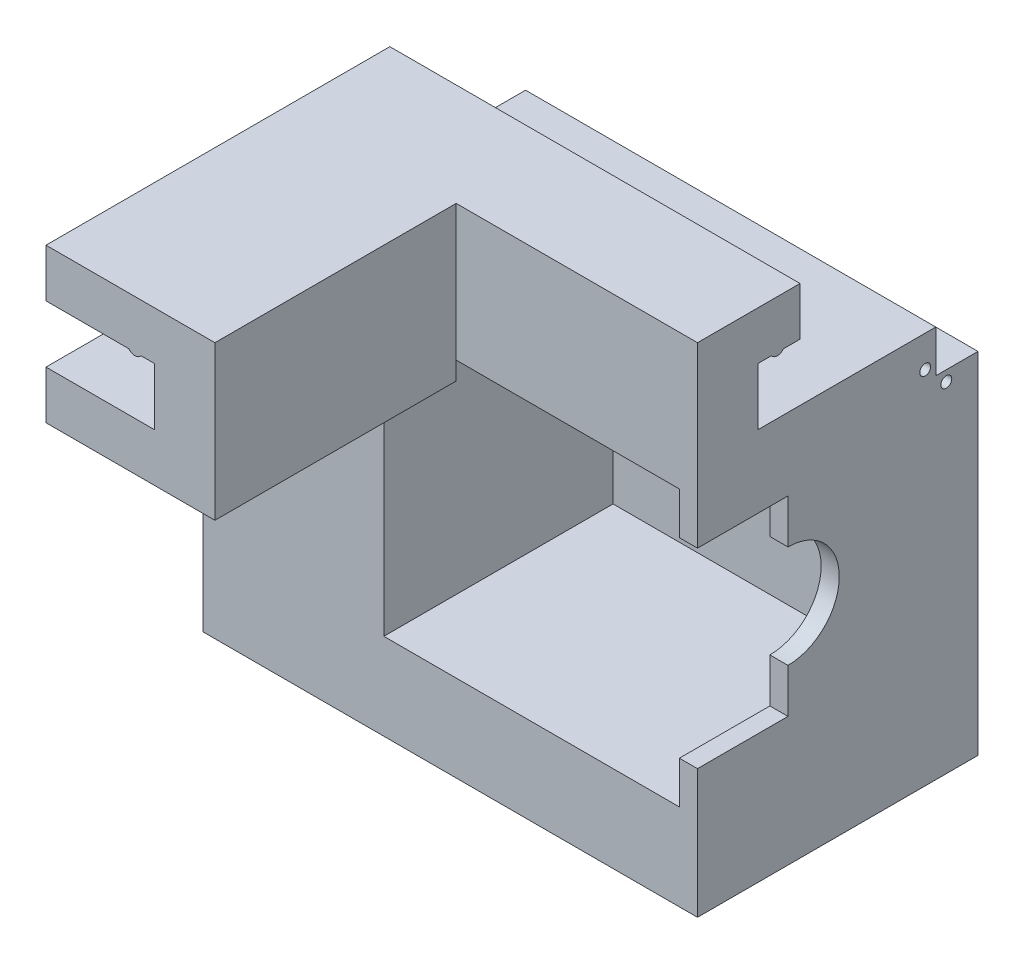
from build123d import *

# Parameters (mm, degrees)
BOSS_EXTRUDE1_DEPTH = 50
SKETCH2_W           = 7
SKETCH2_H           = 8
BOSS_EXTRUDE2_DEPTH = 50
SKETCH2_3_W         = 7
SKETCH2_3_H         = 8
BOSS_EXTRUDE3_DEPTH = 18
SKETCH3_W           = 10
SKETCH3_H           = 63
SKETCH3_W_2         = 7
SKETCH3_H_2         = 8
BOSS_EXTRUDE4_DEPTH = 82
FILLET1_R           = 5
SKETCH4_W           = 49
SKETCH4_H           = 29.5
CUT_EXTRUDE1_DEPTH  = 63
SKETCH5_W           = 29.5
SKETCH5_H           = 11
BOSS_EXTRUDE5_DEPTH = 49
CUT_EXTRUDE2_DEPTH  = 29.5
SKETCH6_R           = 1.75
CUT_EXTRUDE3_DEPTH  = 5
SKETCH6_6_R         = 0.75
CUT_EXTRUDE4_DEPTH  = 15
SKETCH8_W           = 18
SKETCH8_H           = 9.5
CUT_EXTRUDE5_DEPTH  = 40
SKETCH9_W           = 7
SKETCH9_H           = 9.5
CUT_EXTRUDE6_DEPTH  = 45
SKETCH10_W          = 10
SKETCH10_H          = 10
CUT_EXTRUDE7_DEPTH  = 29.5
SKETCH11_W          = 13
SKETCH11_H          = 48
SKETCH11_H_2        = 7
CUT_EXTRUDE8_DEPTH  = 124.13610356
SKETCH12_W          = 8
SKETCH12_H          = 10
CUT_EXTRUDE9_DEPTH  = 114.279521539
SKETCH13_W          = 10
SKETCH13_H          = 6
CUT_EXTRUDE10_DEPTH = 14
SKETCH15_W          = 14
SKETCH15_H          = 6
CUT_EXTRUDE11_DEPTH = 128.218316291
FILLET2_R           = 3
SKETCH17_W          = 49
SKETCH17_H          = 62
BOSS_EXTRUDE6_DEPTH = 46.5
CUT_EXTRUDE12_START = -30
SKETCH18_W          = 45
SKETCH18_H          = 63
CUT_EXTRUDE12_DEPTH = 30
SKETCH19_W          = 45
SKETCH19_H          = 4
SKETCH19_H_2        = 27.35
BOSS_EXTRUDE7_DEPTH = 30
BOSS_EXTRUDE8_DEPTH = 3
SKETCH24_W          = 14
SKETCH24_H          = 10
CUT_EXTRUDE15_DEPTH = 112.778799421
SKETCH26_W          = 42
SKETCH26_H          = 31.65
CUT_EXTRUDE16_DEPTH = 8
SKETCH27_W          = 42
SKETCH27_H          = 38
CUT_EXTRUDE17_DEPTH = 7
SKETCH28_W          = 42
SKETCH28_H          = 38
CUT_EXTRUDE18_DEPTH = 7
SKETCH29_W          = 38
SKETCH29_H          = 45.65
CUT_EXTRUDE19_DEPTH = 7
SKETCH30_W          = 46.5
SKETCH30_H          = 6
CUT_EXTRUDE20_DEPTH = 131.599578866
CUT_EXTRUDE21_DEPTH = 127.610623567
SKETCH32_3_R        = 0.9
SKETCH32_3_R_2      = 0.75
CUT_EXTRUDE22_DEPTH = 6


with BuildPart() as part:
    # Sketch1 → Boss-Extrude1 (new body)
    with BuildSketch(Plane.XY):
        with BuildLine():
            Line((-2.25, -8), (-4.25, -8))
            ThreePointArc((-4.25, -8), (-3.25, -8.5), (-2.25, -8))
        make_face()
        Polygon((10, -25.5), (10, 0), (0, 0), (-18, 0), (-18, -8), (0, -8), (0, -17.5), (-18, -17.5), (-18, -25.5), align=None)
    extrude(amount=BOSS_EXTRUDE1_DEPTH)

    # Sketch2 → Boss-Extrude2 (add)
    with BuildSketch(Plane(origin=(0, 0, 0), x_dir=(0, 0, -1), z_dir=(1, 0, 0))):
        Polygon((7, 0), (0, 0), (0, -8), (2.25, -8), (4.25, -8), (7, -8), align=None)
        Polygon((0, -8), (0, 0), (-10, 0), (-10, -25.5), (0, -25.5), (0, -17.5), align=None)
        with Locations((3.5, -21.5)):
            Rectangle(SKETCH2_W, SKETCH2_H)
        with BuildLine():
            Line((4.25, -8), (2.25, -8))
            ThreePointArc((2.25, -8), (3.25, -8.5), (4.25, -8))
        make_face()
    extrude(amount=BOSS_EXTRUDE2_DEPTH)

    # Sketch2_3 → Boss-Extrude3 (add)
    with BuildSketch(Plane(origin=(0, 0, 0), x_dir=(0, 0, -1), z_dir=(1, 0, 0))):
        Polygon((7, 0), (0, 0), (0, -8), (2.25, -8), (4.25, -8), (7, -8), align=None)
        with Locations((3.5, -21.5)):
            Rectangle(SKETCH2_3_W, SKETCH2_3_H)
    extrude(amount=-BOSS_EXTRUDE3_DEPTH)

    # Sketch3 → Boss-Extrude4 (add)
    with BuildSketch(Plane(origin=(50, 0, 0), x_dir=(0, 0, -1), z_dir=(1, 0, 0))):
        Polygon((36.5, -17.5), (7, -17.5), (7, -25.5), (0, -25.5), (0, -88.5), (36.5, -88.5), align=None)
        with Locations((-5, -57)):
            Rectangle(SKETCH3_W, SKETCH3_H)
        with Locations((3.5, -21.5)):
            Rectangle(SKETCH3_W_2, SKETCH3_H_2)
        with Locations((-5, -21.5)):
            Rectangle(SKETCH3_W, SKETCH3_H_2)
    extrude(amount=-BOSS_EXTRUDE4_DEPTH)

    # Fillet1
    fillet1_edges = [part.edges().sort_by_distance(p)[0] for p in [
        (-32, -17.5, -13.25),
        (-32, -53, -36.5),
        (9, -17.5, -36.5),
    ]]
    fillet(fillet1_edges, radius=FILLET1_R)

    # Sketch4 → Cut-Extrude1 (cut)
    with BuildSketch(Plane.XZ.offset(88.5)):
        with Locations((25.5, -4.75)):
            Rectangle(SKETCH4_W, SKETCH4_H)
    extrude(amount=-CUT_EXTRUDE1_DEPTH, mode=Mode.SUBTRACT)

    # Sketch5 → Boss-Extrude5 (add)
    with BuildSketch(Plane(origin=(50, 0, 0), x_dir=(0, 0, -1), z_dir=(1, 0, 0))):
        with Locations((4.75, -31)):
            Rectangle(SKETCH5_W, SKETCH5_H)
        with Locations((4.75, -83)):
            Rectangle(SKETCH5_W, SKETCH5_H)
    extrude(amount=-BOSS_EXTRUDE5_DEPTH)

    # Sketch7 → Cut-Extrude2 (cut)
    with BuildSketch(Plane.XY.offset(10)):
        Polygon((1, -36.5), (27, -36.5), (27, -26.5), (50, -26.5), (50, -88.5), (27, -88.5), (27, -77.5), (1, -77.5), align=None)
    extrude(amount=-CUT_EXTRUDE2_DEPTH, mode=Mode.SUBTRACT)

    # Sketch6 → Cut-Extrude3 (cut)
    with BuildSketch(Plane(origin=(27, 0, 0), x_dir=(0, 0, -1), z_dir=(1, 0, 0))):
        with Locations((4.25, -81.5)):
            Circle(SKETCH6_R)
        with Locations((14.25, -81.5)):
            Circle(SKETCH6_R)
        with Locations((14.25, -32.5)):
            Circle(SKETCH6_R)
        with Locations((4.25, -32.5)):
            Circle(SKETCH6_R)
    extrude(amount=-CUT_EXTRUDE3_DEPTH, mode=Mode.SUBTRACT)

    # Sketch6_6 → Cut-Extrude4 (cut)
    with BuildSketch(Plane(origin=(27, 0, 0), x_dir=(0, 0, -1), z_dir=(1, 0, 0))):
        with Locations((4.25, -81.5)):
            Circle(SKETCH6_6_R)
        with Locations((14.25, -81.5)):
            Circle(SKETCH6_6_R)
        with Locations((14.25, -32.5)):
            Circle(SKETCH6_6_R)
        with Locations((4.25, -32.5)):
            Circle(SKETCH6_6_R)
    extrude(amount=-CUT_EXTRUDE4_DEPTH, mode=Mode.SUBTRACT)

    # Sketch8 → Cut-Extrude5 (cut)
    with BuildSketch(Plane(origin=(0, 0, -7), x_dir=(-1, 0, 0), z_dir=(0, 0, -1))):
        with Locations((9, -12.75)):
            Rectangle(SKETCH8_W, SKETCH8_H)
    extrude(amount=-CUT_EXTRUDE5_DEPTH, mode=Mode.SUBTRACT)

    # Sketch9 → Cut-Extrude6 (cut)
    with BuildSketch(Plane.ZY.offset(18)):
        with Locations((-3.5, -12.75)):
            Rectangle(SKETCH9_W, SKETCH9_H)
    extrude(amount=-CUT_EXTRUDE6_DEPTH, mode=Mode.SUBTRACT)

    # Sketch10 → Cut-Extrude7 (cut)
    with BuildSketch(Plane.XY.offset(10)):
        with Locations((6, -31.5)):
            Rectangle(SKETCH10_W, SKETCH10_H)
    extrude(amount=-CUT_EXTRUDE7_DEPTH, mode=Mode.SUBTRACT)

    # Sketch11 → Cut-Extrude8 (cut, through all)
    with BuildSketch(Plane.XY.offset(-19.5)):
        with Locations((43.5, -57.5)):
            Rectangle(SKETCH11_W, SKETCH11_H)
        with Locations((43.5, -85)):
            Rectangle(SKETCH11_W, SKETCH11_H_2)
    extrude(amount=-CUT_EXTRUDE8_DEPTH, mode=Mode.SUBTRACT)

    # Sketch12 → Cut-Extrude9 (cut, through all)
    with BuildSketch(Plane.XZ.offset(88.5)):
        with Locations((-28, -31.5)):
            Rectangle(SKETCH12_W, SKETCH12_H)
    extrude(amount=-CUT_EXTRUDE9_DEPTH, mode=Mode.SUBTRACT)

    # Sketch13 → Cut-Extrude10 (cut)
    with BuildSketch(Plane.ZY.offset(32)):
        with Locations((-31.5, -20.5)):
            Rectangle(SKETCH13_W, SKETCH13_H)
    extrude(amount=-CUT_EXTRUDE10_DEPTH, mode=Mode.SUBTRACT)

    # Sketch15 → Cut-Extrude11 (cut, through all)
    with BuildSketch(Plane(origin=(0, 0, -26.5), x_dir=(-1, 0, 0), z_dir=(0, 0, -1))):
        with Locations((25, -20.5)):
            Rectangle(SKETCH15_W, SKETCH15_H)
    extrude(amount=-CUT_EXTRUDE11_DEPTH, mode=Mode.SUBTRACT)

    # Fillet2
    fillet2_edges = [part.edges().sort_by_distance(p)[0] for p in [
        (-24, -56, -26.5),
        (-24, -23.5, -31.5),
        (-28, -23.5, -26.5),
    ]]
    fillet(fillet2_edges, radius=FILLET2_R)

    # Sketch17 → Boss-Extrude6 (add)
    with BuildSketch(Plane.XY.offset(10)):
        with Locations((25.5, -57.5)):
            Rectangle(SKETCH17_W, SKETCH17_H)
    extrude(amount=-BOSS_EXTRUDE6_DEPTH)

    # Sketch18 → Cut-Extrude12 (cut)
    with BuildSketch(Plane.XY.offset(10).offset(CUT_EXTRUDE12_START)):
        with Locations((27.5, -57)):
            Rectangle(SKETCH18_W, SKETCH18_H)
    extrude(amount=CUT_EXTRUDE12_DEPTH, mode=Mode.SUBTRACT)

    # Sketch19 → Boss-Extrude7 (add)
    with BuildSketch(Plane.XY.offset(-20)):
        with Locations((27.5, -27.5)):
            Rectangle(SKETCH19_W, SKETCH19_H)
        with Locations((27.5, -74.825)):
            Rectangle(SKETCH19_W, SKETCH19_H_2)
    extrude(amount=BOSS_EXTRUDE7_DEPTH)

    # Sketch22 → Boss-Extrude8 (add)
    with BuildSketch(Plane(origin=(50, 0, 0), x_dir=(0, 0, -1), z_dir=(1, 0, 0))):
        with BuildLine():
            Line((20, -61.15), (20, -45.325))
            Line((20, -45.325), (13.5, -45.325))
            ThreePointArc((13.5, -45.325), (11.01040764, -51.33540764), (5, -53.825))
            Line((5, -53.825), (5, -61.15))
            Line((5, -61.15), (20, -61.15))
        make_face()
        with BuildLine():
            Line((20, -45.325), (20, -29.5))
            Line((20, -29.5), (5, -29.5))
            Line((5, -29.5), (5, -36.825))
            ThreePointArc((5, -36.825), (11.01040764, -39.31459236), (13.5, -45.325))
            Line((13.5, -45.325), (20, -45.325))
        make_face()
    extrude(amount=-BOSS_EXTRUDE8_DEPTH)

    # Sketch24 → Cut-Extrude15 (cut, through all)
    with BuildSketch(Plane.XY.offset(10)):
        with Locations((-25, -28.5)):
            Rectangle(SKETCH24_W, SKETCH24_H)
    extrude(amount=-CUT_EXTRUDE15_DEPTH, mode=Mode.SUBTRACT)

    # Sketch26 → Cut-Extrude16 (cut)
    with BuildSketch(Plane.XY.offset(-20)):
        with Locations((26, -45.325)):
            Rectangle(SKETCH26_W, SKETCH26_H)
    extrude(amount=-CUT_EXTRUDE16_DEPTH, mode=Mode.SUBTRACT)

    # Sketch27 → Cut-Extrude17 (cut)
    with BuildSketch(Plane.XZ.offset(29.5)):
        with Locations((26, -9)):
            Rectangle(SKETCH27_W, SKETCH27_H)
    extrude(amount=-CUT_EXTRUDE17_DEPTH, mode=Mode.SUBTRACT)

    # Sketch28 → Cut-Extrude18 (cut)
    with BuildSketch(Plane(origin=(0, -61.15, 0), x_dir=(1, 0, 0), z_dir=(0, 1, 0))):
        with Locations((26, 9)):
            Rectangle(SKETCH28_W, SKETCH28_H)
    extrude(amount=-CUT_EXTRUDE18_DEPTH, mode=Mode.SUBTRACT)

    # Sketch29 → Cut-Extrude19 (cut)
    with BuildSketch(Plane(origin=(5, 0, 0), x_dir=(0, 0, -1), z_dir=(1, 0, 0))):
        with Locations((9, -45.325)):
            Rectangle(SKETCH29_W, SKETCH29_H)
    extrude(amount=-CUT_EXTRUDE19_DEPTH, mode=Mode.SUBTRACT)

    # Sketch30 → Cut-Extrude20 (cut, through all)
    with BuildSketch(Plane(origin=(50, 0, 0), x_dir=(0, 0, -1), z_dir=(1, 0, 0))):
        with Locations((13.25, -85.5)):
            Rectangle(SKETCH30_W, SKETCH30_H)
    extrude(amount=-CUT_EXTRUDE20_DEPTH, mode=Mode.SUBTRACT)

    # Sketch32 → Cut-Extrude21 (cut, through all)
    with BuildSketch(Plane(origin=(50, 0, 0), x_dir=(0, 0, -1), z_dir=(1, 0, 0))):
        with BuildLine():
            ThreePointArc((36.5, -22.5), (35.035533906, -18.964466094), (31.5, -17.5))
            Line((31.5, -17.5), (29.5, -17.5))
            Line((29.5, -17.5), (29.5, -20))
            Line((29.5, -20), (29.5, -21))
            Line((29.5, -21), (29.5, -24.5))
            Line((29.5, -24.5), (33, -24.5))
            Line((33, -24.5), (34.1, -24.5))
            Line((34.1, -24.5), (35.4, -24.5))
            Line((35.4, -24.5), (36.5, -24.5))
            Line((36.5, -24.5), (36.5, -22.5))
        make_face()
    extrude(amount=-CUT_EXTRUDE21_DEPTH, mode=Mode.SUBTRACT)

    # Sketch32_3 → Cut-Extrude22 (cut)
    with BuildSketch(Plane(origin=(50, 0, 0), x_dir=(0, 0, -1), z_dir=(1, 0, 0))):
        with Locations((27.75, -22.75)):
            Circle(SKETCH32_3_R)
        with Locations((27.75, -22.75)):
            Circle(SKETCH32_3_R_2, mode=Mode.SUBTRACT)
        with Locations((27.75, -22.75)):
            Circle(SKETCH32_3_R_2)
        with Locations((31.25, -26.25)):
            Circle(SKETCH32_3_R)
        with Locations((31.25, -26.25)):
            Circle(SKETCH32_3_R_2, mode=Mode.SUBTRACT)
        with Locations((31.25, -26.25)):
            Circle(SKETCH32_3_R_2)
    extrude(amount=-CUT_EXTRUDE22_DEPTH, mode=Mode.SUBTRACT)


solid = part.part
